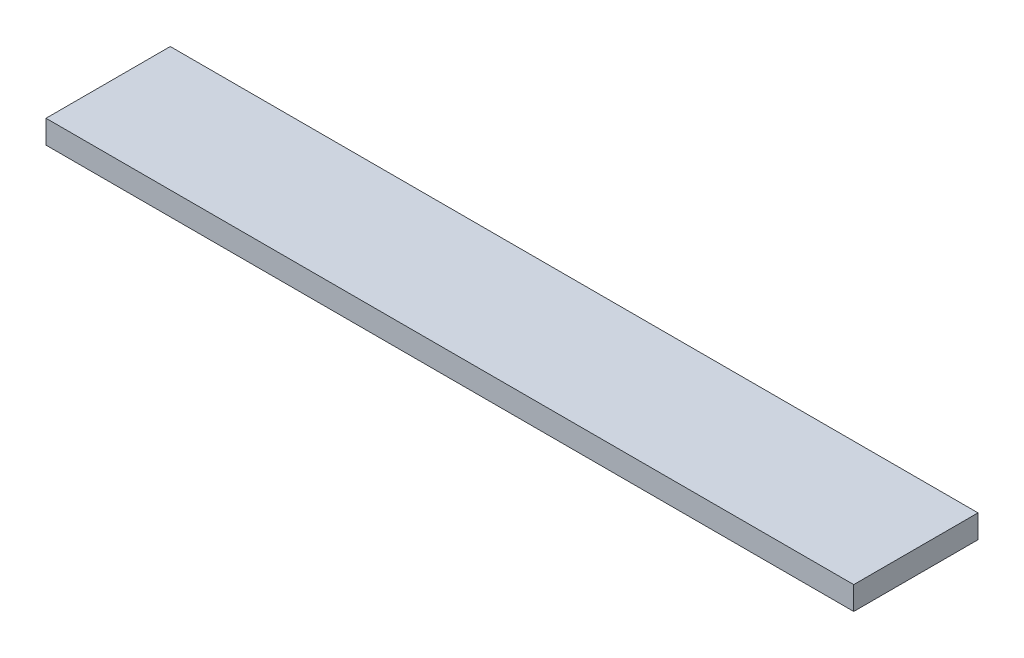
from build123d import *

# Parameters (mm, degrees)
SKETCH1_W           = 165.1
SKETCH1_H           = 25.4
BOSS_EXTRUDE1_DEPTH = 4.7625


with BuildPart() as part:
    # Sketch1 → Boss-Extrude1 (new body)
    with BuildSketch(Plane(origin=(0, 0, 0), x_dir=(1, 0, 0), z_dir=(0, 1, 0))):
        with Locations((82.55, -12.7)):
            Rectangle(SKETCH1_W, SKETCH1_H)
    extrude(amount=BOSS_EXTRUDE1_DEPTH)


solid = part.part
